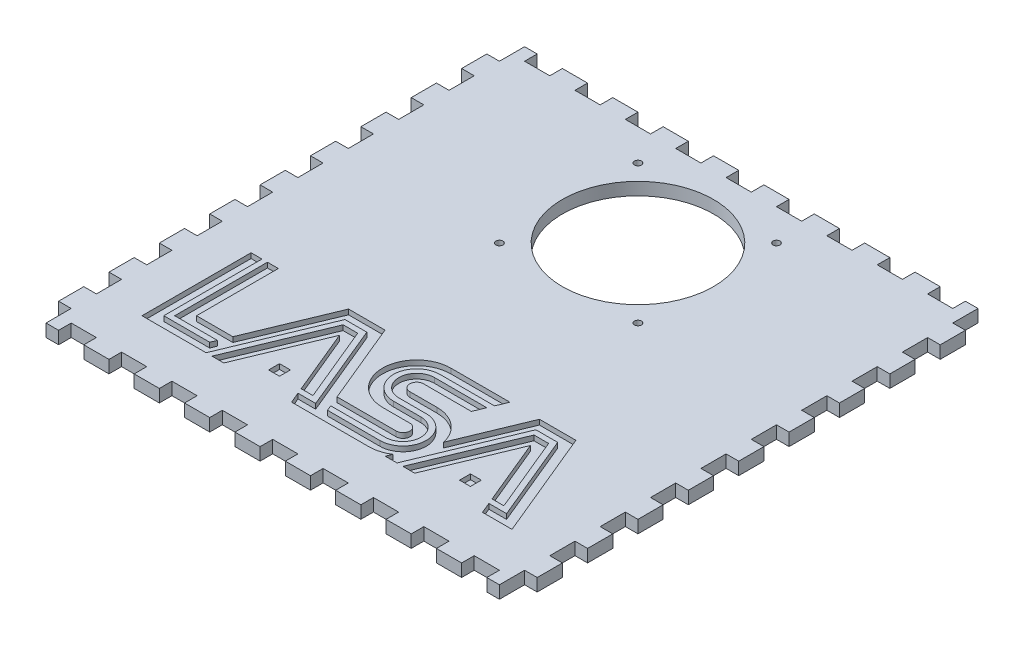
from build123d import *

# Parameters (mm, degrees)
SKETCH1_W           = 241.3
SKETCH1_H           = 241.3
BOSS_EXTRUDE1_DEPTH = 6.35
SKETCH2_W           = 6.35
SKETCH2_H           = 12.7
CUT_EXTRUDE1_DEPTH  = 7.35
LPATTERN1_COUNT     = 10
LPATTERN1_PITCH     = 25.4
SKETCH3_W           = 12.7
SKETCH3_H           = 6.35
CUT_EXTRUDE2_DEPTH  = 7.35
LPATTERN2_COUNT     = 9
LPATTERN2_PITCH     = 25.4
SKETCH4_R           = 38.1
CUT_EXTRUDE3_DEPTH  = 7.35
SKETCH8_W           = 5.5
SKETCH8_H           = 5.5
CUT_EXTRUDE4_DEPTH  = 2.54
SKETCH9_R           = 1.75
CUT_EXTRUDE5_DEPTH  = 7.35
CIRPATTERN1_COUNT   = 4


with BuildPart() as part:
    # Sketch1 → Boss-Extrude1 (new body)
    with BuildSketch(Plane(origin=(0, 0, 0), x_dir=(1, 0, 0), z_dir=(0, 1, 0))):
        with Locations((120.65, 120.65)):
            Rectangle(SKETCH1_W, SKETCH1_H)
    extrude(amount=BOSS_EXTRUDE1_DEPTH)

    # Sketch2 → Cut-Extrude1 (cut, through all)
    with BuildSketch(Plane(origin=(0, 6.35, 0), x_dir=(1, 0, 0), z_dir=(0, 1, 0))):
        with Locations((3.175, 234.95)):
            Rectangle(SKETCH2_W, SKETCH2_H)
        with Locations((238.125, 234.95)):
            Rectangle(SKETCH2_W, SKETCH2_H)
    cut_extrude1 = extrude(amount=-CUT_EXTRUDE1_DEPTH, mode=Mode.SUBTRACT)

    # LPattern1: Cut-Extrude1 ×10
    with Locations(*[(0, 0, i * LPATTERN1_PITCH) for i in range(1, LPATTERN1_COUNT)]):
        add(cut_extrude1, mode=Mode.SUBTRACT)

    # Sketch3 → Cut-Extrude2 (cut, through all)
    with BuildSketch(Plane(origin=(0, 6.35, 0), x_dir=(1, 0, 0), z_dir=(0, 1, 0))):
        with Locations((19.05, 3.175)):
            Rectangle(SKETCH3_W, SKETCH3_H)
        with Locations((19.05, 238.125)):
            Rectangle(SKETCH3_W, SKETCH3_H)
    cut_extrude2 = extrude(amount=-CUT_EXTRUDE2_DEPTH, mode=Mode.SUBTRACT)

    # LPattern2: Cut-Extrude2 ×9
    with Locations(*[(i * LPATTERN2_PITCH, 0, 0) for i in range(1, LPATTERN2_COUNT)]):
        add(cut_extrude2, mode=Mode.SUBTRACT)

    # Sketch4 → Cut-Extrude3 (cut, through all)
    with BuildSketch(Plane(origin=(0, 6.35, 0), x_dir=(1, 0, 0), z_dir=(0, 1, 0))):
        with Locations((120.65, 184.15)):
            Circle(SKETCH4_R)
    extrude(amount=-CUT_EXTRUDE3_DEPTH, mode=Mode.SUBTRACT)

    # Sketch8 → Cut-Extrude4 (cut)
    with BuildSketch(Plane(origin=(0, 6.35, 0), x_dir=(1, 0, 0), z_dir=(0, 1, 0))):
        with BuildLine():
            Line((35.62231, 82.37231016), (41.12231, 82.37231016))
            Line((41.12231, 82.37231016), (41.12231, 41.12231))
            Line((41.12231, 41.12231), (59.434853729, 41.12231))
            Line((59.434853729, 41.12231), (76.521163177, 82.37231))
            Line((76.521163177, 82.37231), (94.896075719, 82.37231))
            Line((94.896075719, 82.37231), (111.982385167, 41.12231))
            Line((111.982385167, 41.12231), (141.810433642, 41.12231))
            ThreePointArc((141.810433642, 41.12231), (145.24793445, 44.55981), (141.810433642, 47.99731))
            Line((141.810433642, 47.99731), (128.060433642, 47.99731))
            ThreePointArc((128.060433642, 47.99731), (110.872934407, 65.18481), (128.060433642, 82.37231))
            Line((128.060433642, 82.37231), (157.888270422, 82.37231))
            Line((157.888270422, 82.37231), (155.610095829, 76.87231))
            Line((155.610095829, 76.87231), (128.060433642, 76.87231))
            ThreePointArc((128.060433642, 76.87231), (116.372934407, 65.18481), (128.060433642, 53.49731))
            Line((128.060433642, 53.49731), (141.810433642, 53.49731))
            ThreePointArc((141.810433642, 53.49731), (150.74793445, 44.55981), (141.810433642, 35.62231))
            Line((141.810433642, 35.62231), (114.26055976, 35.62231))
            Line((114.26055976, 35.62231), (115.399647057, 32.87231))
            Line((115.399647057, 32.87231), (141.810433642, 32.87231))
            ThreePointArc((141.810433642, 32.87231), (153.49793445, 44.55981), (141.810433642, 56.24731))
            Line((141.810433642, 56.24731), (128.060433642, 56.24731))
            ThreePointArc((128.060433642, 56.24731), (119.122934407, 65.18481), (128.060433642, 74.12231))
            Line((128.060433642, 74.12231), (154.471008533, 74.12231))
            Line((154.471008533, 74.12231), (152.19283394, 68.62231))
            Line((152.19283394, 68.62231), (128.060433642, 68.62231))
            ThreePointArc((128.060433642, 68.62231), (124.622934407, 65.18481), (128.060433642, 61.74731))
            Line((128.060433642, 61.74731), (141.810433642, 61.74731))
            ThreePointArc((141.810433642, 61.74731), (152.605713785, 57.934117472), (158.610944882, 48.18651725))
            Line((158.610944882, 48.18651725), (172.771163949, 82.372310167))
            Line((172.771163949, 82.372310167), (191.146076492, 82.372310167))
            Line((191.146076492, 82.372310167), (213.927822422, 27.372310167))
            Line((213.927822422, 27.372310167), (199.044929668, 27.372310167))
            Line((199.044929668, 27.372310167), (196.766755075, 32.872310167))
            Line((196.766755075, 32.872310167), (205.696490727, 32.872310167))
            Line((205.696490727, 32.872310167), (187.471093983, 76.872310167))
            Line((187.471093983, 76.872310167), (176.446146457, 76.872310167))
            Line((176.446146457, 76.872310167), (155.94257512, 27.372310167))
            Line((155.94257512, 27.372310167), (149.989418018, 27.372310167))
            Line((149.989418018, 27.372310167), (151.125720122, 30.115586115))
            ThreePointArc((151.125720122, 30.115586115), (146.665846252, 28.072386702), (141.810433642, 27.37231016))
            Line((141.810433642, 27.37231016), (102.794928896, 27.37231016))
            Line((102.794928896, 27.37231016), (100.516754303, 32.87231016))
            Line((100.516754303, 32.87231016), (109.446489955, 32.87231016))
            Line((109.446489955, 32.87231016), (91.221093211, 76.87231016))
            Line((91.221093211, 76.87231016), (80.196145685, 76.87231016))
            Line((80.196145685, 76.87231016), (59.692574348, 27.37231016))
            Line((59.692574348, 27.37231016), (27.37231, 27.37231016))
            Line((27.37231, 27.37231016), (27.37231, 82.37231016))
            Line((27.37231, 82.37231016), (32.87231, 82.37231016))
            Line((32.87231, 82.37231016), (32.87231, 32.87231016))
            Line((32.87231, 32.87231016), (56.017591839, 32.87231016))
            Line((56.017591839, 32.87231016), (57.156679136, 35.62231016))
            Line((57.156679136, 35.62231016), (35.62231, 35.62231016))
            Line((35.62231, 35.62231016), (35.62231, 82.37231016))
        make_face()
        with Locations((85.708619448, 38.37231)):
            Rectangle(SKETCH8_W, SKETCH8_H)
        with Locations((181.958619448, 38.37231)):
            Rectangle(SKETCH8_W, SKETCH8_H)
        Polygon((178.283636939, 74.12231), (185.633601956, 74.12231), (201.580824108, 35.62231), (195.627667006, 35.62231), (181.958619448, 68.62231), (164.87231, 27.37231), (158.919152898, 27.37231), align=None)
        Polygon((85.708619448, 68.62231), (99.377667006, 35.62231), (105.330824108, 35.62231), (89.383601956, 74.12231), (82.033636939, 74.12231), (62.669152898, 27.37231), (68.62231, 27.37231), align=None)
    extrude(amount=-CUT_EXTRUDE4_DEPTH, mode=Mode.SUBTRACT)

    # Sketch9 → Cut-Extrude5 (cut, through all)
    with BuildSketch(Plane(origin=(0, 6.35, 0), x_dir=(1, 0, 0), z_dir=(0, 1, 0))):
        with Locations((85.725, 219.075)):
            Circle(SKETCH9_R)
    cut_extrude5 = extrude(amount=-CUT_EXTRUDE5_DEPTH, mode=Mode.SUBTRACT)

    # CirPattern1: Cut-Extrude5 ×4 about axis
    cirpattern1_axis = Axis((120.65, 0, -184.15), (0, 1, 0))
    for i in range(1, CIRPATTERN1_COUNT):
        add(cut_extrude5.rotate(cirpattern1_axis, i * 360 / CIRPATTERN1_COUNT), mode=Mode.SUBTRACT)


solid = part.part
